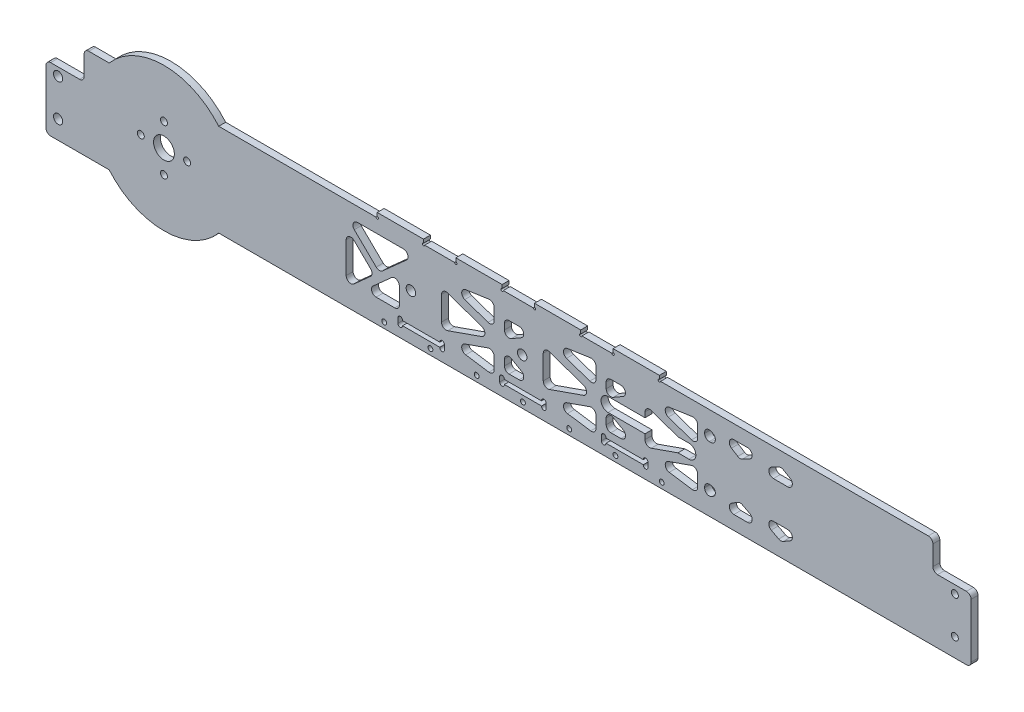
from build123d import *

# Parameters (mm, degrees)
SKETCH_1_W           = 368
SKETCH_1_H           = 40
EXTRUDE_1_DEPTH      = 3
SKETCH_2_W           = 16
SKETCH_2_H           = 27.5
EXTRUDE_2_DEPTH      = 3
SKETCH_3_R           = 4.5
SKETCH_3_R_2         = 1.5
SKETCH_3_R_3         = 3
SKETCH_3_R_4         = 2
CUT_EXTRUDE_1_DEPTH  = 4
SKETCH_5_R           = 1.5
CUT_EXTRUDE_3_DEPTH  = 3
SKETCH_6_W           = 0.5
SKETCH_6_H           = 12.5
CUT_EXTRUDE_4_DEPTH  = 10
SKETCH_8_R           = 31
SKETCH_8_R_2         = 1.5
SKETCH_8_R_3         = 4.5
EXTRUDE_3_DEPTH      = 3
CUT_EXTRUDE_7_DEPTH  = 10
SKETCH_11_R          = 2.05
CUT_EXTRUDE_8_DEPTH  = 10
SKETCH_12_R          = 1.05
CUT_EXTRUDE_9_DEPTH  = 10
SKETCH_14_W          = 20
SKETCH_14_H          = 2
EXTRUDE_4_DEPTH      = 3
SKETCH_15_W          = 20.1
SKETCH_15_H          = 2.1
CUT_EXTRUDE_10_DEPTH = 4
CUT_EXTRUDE_11_DEPTH = 10
SKETCH_17_R          = 1
CUT_EXTRUDE_12_DEPTH = 10
FILLET_1_R           = 2
SKETCH_18_W          = 16.1
SKETCH_18_H          = 0.1
EXTRUDE_5_DEPTH      = 3
SKETCH_19_R          = 0.5
CUT_EXTRUDE_13_DEPTH = 10


with BuildPart() as part:
    # 草图1 → 凸台-拉伸1 (new body)
    with BuildSketch(Plane.XY):
        Rectangle(SKETCH_1_W, SKETCH_1_H)
    extrude(amount=EXTRUDE_1_DEPTH)

    # 草图2 → 凸台-拉伸2 (add)
    with BuildSketch(Plane.XY):
        with Locations((-192, -6.25)):
            Rectangle(SKETCH_2_W, SKETCH_2_H)
        with Locations((192, -6.25)):
            Rectangle(SKETCH_2_W, SKETCH_2_H)
    extrude(amount=EXTRUDE_2_DEPTH)

    # 草图3 → 切除-拉伸1 (cut, through all)
    with BuildSketch(Plane.XY.offset(3)):
        with Locations((-149, 0)):
            Circle(SKETCH_3_R)
        with Locations((193, 4)):
            Circle(SKETCH_3_R_2)
        with Locations((193, -12)):
            Circle(SKETCH_3_R_2)
        with Locations((68, 0)):
            Circle(SKETCH_3_R_3)
        with Locations((-194.762498553, -12)):
            Circle(SKETCH_3_R_4)
        with Locations((-194.762498553, 4)):
            Circle(SKETCH_3_R_4)
    extrude(amount=-CUT_EXTRUDE_1_DEPTH, mode=Mode.SUBTRACT)

    # 草图5 → 切除-拉伸3 (cut)
    with BuildSketch(Plane.XY.offset(3)):
        with Locations((-159, 0)):
            Circle(SKETCH_5_R)
        with Locations((-149, 10)):
            Circle(SKETCH_5_R)
        with Locations((-139, 0)):
            Circle(SKETCH_5_R)
        with Locations((-149, -10)):
            Circle(SKETCH_5_R)
    extrude(amount=-CUT_EXTRUDE_3_DEPTH, mode=Mode.SUBTRACT)

    # 草图6 → 切除-拉伸4 (cut)
    with BuildSketch(Plane.XY.offset(3)):
        with Locations((-183.75, 13.75)):
            Rectangle(SKETCH_6_W, SKETCH_6_H)
        with Locations((183.75, 13.75)):
            Rectangle(SKETCH_6_W, SKETCH_6_H)
    extrude(amount=-CUT_EXTRUDE_4_DEPTH, mode=Mode.SUBTRACT)

    # 草图8 → 凸台-拉伸3 (add)
    with BuildSketch(Plane.XY.offset(3)):
        with Locations((-149, 0)):
            Circle(SKETCH_8_R)
        with Locations((-139, 0)):
            Circle(SKETCH_8_R_2, mode=Mode.SUBTRACT)
        with Locations((-149, -10)):
            Circle(SKETCH_8_R_2, mode=Mode.SUBTRACT)
        with Locations((-159, 0)):
            Circle(SKETCH_8_R_2, mode=Mode.SUBTRACT)
        with Locations((-149, 10)):
            Circle(SKETCH_8_R_2, mode=Mode.SUBTRACT)
        with Locations((-149, 0)):
            Circle(SKETCH_8_R_3, mode=Mode.SUBTRACT)
    extrude(amount=-EXTRUDE_3_DEPTH)

    # 草图10 → 切除-拉伸7 (cut)
    with BuildSketch(Plane.XY.offset(3)):
        with BuildLine():
            Line((43, 3), (78, 3))
            ThreePointArc((78, 3), (81, 0), (78, -3))
            Line((78, -3), (43, -3))
            ThreePointArc((43, -3), (40, 0), (43, 3))
        make_face()
    extrude(amount=-CUT_EXTRUDE_7_DEPTH, mode=Mode.SUBTRACT)

    # 草图11 → 切除-拉伸8 (cut)
    with BuildSketch(Plane(origin=(0, 0, 0), x_dir=(-1, 0, 0), z_dir=(0, 0, -1))):
        with Locations((-53.224408026, 0)):
            Circle(SKETCH_11_R)
        with Locations((42.205591974, 0)):
            Circle(SKETCH_11_R)
        with Locations((-5.901908026, 0)):
            Circle(SKETCH_11_R)
    extrude(amount=-CUT_EXTRUDE_8_DEPTH, mode=Mode.SUBTRACT)

    # 草图12 → 切除-拉伸9 (cut)
    with BuildSketch(Plane(origin=(0, 0, 0), x_dir=(-1, 0, 0), z_dir=(0, 0, -1))):
        with Locations((-66.224408026, -17.5)):
            Circle(SKETCH_12_R)
        with Locations((-46.224408026, -17.5)):
            Circle(SKETCH_12_R)
        with Locations((-26.224408026, -17.5)):
            Circle(SKETCH_12_R)
        with Locations((-6.224408026, -17.5)):
            Circle(SKETCH_12_R)
        with Locations((13.775591974, -17.5)):
            Circle(SKETCH_12_R)
        with Locations((33.775591974, -17.5)):
            Circle(SKETCH_12_R)
        with Locations((53.775591974, -17.5)):
            Circle(SKETCH_12_R)
    extrude(amount=-CUT_EXTRUDE_9_DEPTH, mode=Mode.SUBTRACT)

    # 草图14 → 凸台-拉伸4 (add)
    with BuildSketch(Plane.XY.offset(3)):
        with Locations((55.224408026, 21)):
            Rectangle(SKETCH_14_W, SKETCH_14_H)
        with Locations((21.224408026, 21)):
            Rectangle(SKETCH_14_W, SKETCH_14_H)
        with Locations((-12.775591974, 21)):
            Rectangle(SKETCH_14_W, SKETCH_14_H)
        with Locations((-46.775591974, 21)):
            Rectangle(SKETCH_14_W, SKETCH_14_H)
    extrude(amount=-EXTRUDE_4_DEPTH)

    # 草图15 → 切除-拉伸10 (cut, through all)
    with BuildSketch(Plane.XY.offset(3)):
        with Locations((50.224408026, -14)):
            Rectangle(SKETCH_15_W, SKETCH_15_H)
        with Locations((6.224408026, -14)):
            Rectangle(SKETCH_15_W, SKETCH_15_H)
        with Locations((-37.775591974, -14)):
            Rectangle(SKETCH_15_W, SKETCH_15_H)
    extrude(amount=-CUT_EXTRUDE_10_DEPTH, mode=Mode.SUBTRACT)

    # 草图16 → 切除-拉伸11 (cut)
    with BuildSketch(Plane(origin=(0, 0, 0), x_dir=(-1, 0, 0), z_dir=(0, 0, -1))):
        with BuildLine():
            Line((-104.299524502, 10.233433981), (-101.10955932, 8.540223685))
            ThreePointArc((-101.10955932, 8.540223685), (-100.102484581, 8.307993961), (-99.113940393, 8.609507749))
            Line((-99.113940393, 8.609507749), (-96.397473263, 10.302718045))
            ThreePointArc((-96.397473263, 10.302718045), (-95.532580053, 12.550198187), (-97.455411807, 14))
            Line((-97.455411807, 14), (-103.36184412, 14))
            ThreePointArc((-103.36184412, 14), (-105.302608408, 12.48315006), (-104.299524502, 10.233433981))
        make_face()
        with BuildLine():
            Line((-113.586675144, 11.766566019), (-116.81600985, 13.480673371))
            ThreePointArc((-116.81600985, 13.480673371), (-117.789309871, 13.713790137), (-118.753690233, 13.44615816))
            Line((-118.753690233, 13.44615816), (-121.722611256, 11.732050808))
            ThreePointArc((-121.722611256, 11.732050808), (-122.654462909, 9.48236191), (-120.722611256, 8))
            Line((-120.722611256, 8), (-114.524355526, 8))
            ThreePointArc((-114.524355526, 8), (-112.583591239, 9.51684994), (-113.586675144, 11.766566019))
        make_face()
        with BuildLine():
            Line((-49.584424063, 6.270311383), (-45.232211414, 3.743861811))
            ThreePointArc((-45.232211414, 3.743861811), (-43.23017334, 3.740322135), (-42.228131095, 5.473550429))
            Line((-42.228131095, 5.473550429), (-42.228131095, 8))
            ThreePointArc((-42.228131095, 8), (-42.813917532, 9.414213562), (-44.228131095, 10))
            Line((-44.228131095, 10), (-48.580343744, 10))
            ThreePointArc((-48.580343744, 10), (-50.51158392, 8.519914784), (-49.584424063, 6.270311383))
        make_face()
        with BuildLine():
            Line((-59.009408026, -5.178088408), (-59.009408026, 5.178088408))
            ThreePointArc((-59.009408026, 5.178088408), (-59.85293214, 6.809824762), (-61.671971552, 7.065152152))
            Line((-61.671971552, 7.065152152), (-76.4198146, 1.887063744))
            ThreePointArc((-76.4198146, 1.887063744), (-77.757251074, 0), (-76.4198146, -1.887063744))
            Line((-76.4198146, -1.887063744), (-61.671971552, -7.065152152))
            ThreePointArc((-61.671971552, -7.065152152), (-59.85293214, -6.809824762), (-59.009408026, -5.178088408))
        make_face()
        with BuildLine():
            Line((-79.131844499, 4.791990705), (-69.094439101, 8.316205898))
            ThreePointArc((-69.094439101, 8.316205898), (-67.766139944, 10.394229783), (-69.465227173, 12.181871948))
            Line((-69.465227173, 12.181871948), (-79.502632571, 13.662042329))
            ThreePointArc((-79.502632571, 13.662042329), (-81.10139867, 13.197301132), (-81.794408026, 11.683440024))
            Line((-81.794408026, 11.683440024), (-81.794408026, 6.679054449))
            ThreePointArc((-81.794408026, 6.679054449), (-80.950883911, 5.047318096), (-79.131844499, 4.791990705))
        make_face()
        with BuildLine():
            Line((-87.430787839, 8), (-86.794408026, 8))
            ThreePointArc((-86.794408026, 8), (-85.380194463, 8.585786438), (-84.794408026, 10))
            Line((-84.794408026, 10), (-84.794408026, 10.396664049))
            ThreePointArc((-84.794408026, 10.396664049), (-85.823809522, 12.145360291), (-87.85234657, 12.093946005))
            Line((-87.85234657, 12.093946005), (-88.488726383, 11.697281955))
            ThreePointArc((-88.488726383, 11.697281955), (-89.353619593, 9.449801813), (-87.430787839, 8))
        make_face()
        with BuildLine():
            Line((58.591786114, -6.45888277), (50.538472091, 0.739814907))
            ThreePointArc((50.538472091, 0.739814907), (48.388817903, 1.074315413), (47.205591974, -0.751302323))
            Line((47.205591974, -0.751302323), (47.205591974, -7.95))
            ThreePointArc((47.205591974, -7.95), (47.791378412, -9.364213562), (49.205591974, -9.95))
            Line((49.205591974, -9.95), (57.258905997, -9.95))
            ThreePointArc((57.258905997, -9.95), (59.127359162, -8.663360197), (58.591786114, -6.45888277))
        make_face()
        with BuildLine():
            Line((59.705451363, -3.430537552), (66.872711857, -9.837209554))
            ThreePointArc((66.872711857, -9.837209554), (69.022366045, -10.17171006), (70.205591974, -8.346092324))
            Line((70.205591974, -8.346092324), (70.205591974, 5.058907845))
            ThreePointArc((70.205591974, 5.058907845), (68.981962411, 6.902070601), (66.808343029, 6.489884919))
            Line((66.808343029, 6.489884919), (59.641082535, -0.508443249))
            ThreePointArc((59.641082535, -0.508443249), (59.038816551, -1.983466277), (59.705451363, -3.430537552))
        make_face()
        with BuildLine():
            Line((65.294545755, 14), (45.444048433, 14))
            ThreePointArc((45.444048433, 14), (43.575595268, 12.713360197), (44.111168316, 10.50888277))
            Line((44.111168316, 10.50888277), (54.474487435, 1.245317353))
            ThreePointArc((54.474487435, 1.245317353), (55.851413506, 0.736919653), (57.204616497, 1.305457509))
            Line((57.204616497, 1.305457509), (66.6917947, 10.569022926))
            ThreePointArc((66.6917947, 10.569022926), (67.146835439, 12.754336083), (65.294545755, 14))
        make_face()
        with BuildLine():
            Line((-44.228131095, -10), (-48.580343744, -10))
            ThreePointArc((-48.580343744, -10), (-50.51158392, -8.519914784), (-49.584424063, -6.270311383))
            Line((-49.584424063, -6.270311383), (-45.232211414, -3.743861811))
            ThreePointArc((-45.232211414, -3.743861811), (-43.23017334, -3.740322135), (-42.228131095, -5.473550429))
            Line((-42.228131095, -5.473550429), (-42.228131095, -8))
            ThreePointArc((-42.228131095, -8), (-42.813917532, -9.414213562), (-44.228131095, -10))
        make_face()
        with BuildLine():
            Line((-79.131844499, -4.791990705), (-69.094439101, -8.316205898))
            ThreePointArc((-69.094439101, -8.316205898), (-67.766139944, -10.394229783), (-69.465227173, -12.181871948))
            Line((-69.465227173, -12.181871948), (-79.502632571, -13.662042329))
            ThreePointArc((-79.502632571, -13.662042329), (-81.10139867, -13.197301132), (-81.794408026, -11.683440024))
            Line((-81.794408026, -11.683440024), (-81.794408026, -6.679054449))
            ThreePointArc((-81.794408026, -6.679054449), (-80.950883911, -5.047318096), (-79.131844499, -4.791990705))
        make_face()
        with BuildLine():
            Line((-104.299524502, -10.233433981), (-101.10955932, -8.540223685))
            ThreePointArc((-101.10955932, -8.540223685), (-100.102484581, -8.307993961), (-99.113940393, -8.609507749))
            Line((-99.113940393, -8.609507749), (-96.397473263, -10.302718045))
            ThreePointArc((-96.397473263, -10.302718045), (-95.532580053, -12.550198187), (-97.455411807, -14))
            Line((-97.455411807, -14), (-103.36184412, -14))
            ThreePointArc((-103.36184412, -14), (-105.302608408, -12.48315006), (-104.299524502, -10.233433981))
        make_face()
        with BuildLine():
            Line((-120.722611256, -8), (-114.524355526, -8))
            ThreePointArc((-114.524355526, -8), (-112.583591239, -9.51684994), (-113.586675144, -11.766566019))
            Line((-113.586675144, -11.766566019), (-116.81600985, -13.480673371))
            ThreePointArc((-116.81600985, -13.480673371), (-117.789309871, -13.713790137), (-118.753690233, -13.44615816))
            Line((-118.753690233, -13.44615816), (-121.722611256, -11.732050808))
            ThreePointArc((-121.722611256, -11.732050808), (-122.654462909, -9.48236191), (-120.722611256, -8))
        make_face()
        with BuildLine():
            Line((-87.85234657, -12.093946005), (-88.488726383, -11.697281955))
            ThreePointArc((-88.488726383, -11.697281955), (-89.353619593, -9.449801813), (-87.430787839, -8))
            Line((-87.430787839, -8), (-86.794408026, -8))
            ThreePointArc((-86.794408026, -8), (-85.380194463, -8.585786438), (-84.794408026, -10))
            Line((-84.794408026, -10), (-84.794408026, -10.396664049))
            ThreePointArc((-84.794408026, -10.396664049), (-85.823809522, -12.145360291), (-87.85234657, -12.093946005))
        make_face()
        with BuildLine():
            Line((-35.131844499, 4.791990705), (-25.094439101, 8.316205898))
            ThreePointArc((-25.094439101, 8.316205898), (-23.766139944, 10.394229783), (-25.465227173, 12.181871948))
            Line((-25.465227173, 12.181871948), (-35.502632571, 13.662042329))
            ThreePointArc((-35.502632571, 13.662042329), (-37.10139867, 13.197301132), (-37.794408026, 11.683440024))
            Line((-37.794408026, 11.683440024), (-37.794408026, 6.679054449))
            ThreePointArc((-37.794408026, 6.679054449), (-36.950883911, 5.047318096), (-35.131844499, 4.791990705))
        make_face()
        with BuildLine():
            Line((-17.671971552, 7.065152152), (-32.4198146, 1.887063744))
            ThreePointArc((-32.4198146, 1.887063744), (-33.757251074, 0), (-32.4198146, -1.887063744))
            Line((-32.4198146, -1.887063744), (-17.671971552, -7.065152152))
            ThreePointArc((-17.671971552, -7.065152152), (-15.85293214, -6.809824762), (-15.009408026, -5.178088408))
            Line((-15.009408026, -5.178088408), (-15.009408026, 5.178088408))
            ThreePointArc((-15.009408026, 5.178088408), (-15.85293214, 6.809824762), (-17.671971552, 7.065152152))
        make_face()
        with BuildLine():
            Line((-35.131844499, -4.791990705), (-25.094439101, -8.316205898))
            ThreePointArc((-25.094439101, -8.316205898), (-23.766139944, -10.394229783), (-25.465227173, -12.181871948))
            Line((-25.465227173, -12.181871948), (-35.502632571, -13.662042329))
            ThreePointArc((-35.502632571, -13.662042329), (-37.10139867, -13.197301132), (-37.794408026, -11.683440024))
            Line((-37.794408026, -11.683440024), (-37.794408026, -6.679054449))
            ThreePointArc((-37.794408026, -6.679054449), (-36.950883911, -5.047318096), (-35.131844499, -4.791990705))
        make_face()
        with BuildLine():
            Line((-5.584424063, -6.270311383), (-1.232211414, -3.743861811))
            ThreePointArc((-1.232211414, -3.743861811), (0.76982666, -3.740322135), (1.771868905, -5.473550429))
            Line((1.771868905, -5.473550429), (1.771868905, -8))
            ThreePointArc((1.771868905, -8), (1.186082468, -9.414213562), (-0.228131095, -10))
            Line((-0.228131095, -10), (-4.580343744, -10))
            ThreePointArc((-4.580343744, -10), (-6.51158392, -8.519914784), (-5.584424063, -6.270311383))
        make_face()
        with BuildLine():
            Line((-5.584424063, 6.270311383), (-1.232211414, 3.743861811))
            ThreePointArc((-1.232211414, 3.743861811), (0.76982666, 3.740322135), (1.771868905, 5.473550429))
            Line((1.771868905, 5.473550429), (1.771868905, 8))
            ThreePointArc((1.771868905, 8), (1.186082468, 9.414213562), (-0.228131095, 10))
            Line((-0.228131095, 10), (-4.580343744, 10))
            ThreePointArc((-4.580343744, 10), (-6.51158392, 8.519914784), (-5.584424063, 6.270311383))
        make_face()
        with BuildLine():
            Line((8.868155501, 4.791990705), (18.905560899, 8.316205898))
            ThreePointArc((18.905560899, 8.316205898), (20.233860056, 10.394229783), (18.534772827, 12.181871948))
            Line((18.534772827, 12.181871948), (8.497367429, 13.662042329))
            ThreePointArc((8.497367429, 13.662042329), (6.89860133, 13.197301132), (6.205591974, 11.683440024))
            Line((6.205591974, 11.683440024), (6.205591974, 6.679054449))
            ThreePointArc((6.205591974, 6.679054449), (7.049116089, 5.047318096), (8.868155501, 4.791990705))
        make_face()
        with BuildLine():
            Line((26.328028448, 7.065152152), (11.5801854, 1.887063744))
            ThreePointArc((11.5801854, 1.887063744), (10.242748926, 0), (11.5801854, -1.887063744))
            Line((11.5801854, -1.887063744), (26.328028448, -7.065152152))
            ThreePointArc((26.328028448, -7.065152152), (28.14706786, -6.809824762), (28.990591974, -5.178088408))
            Line((28.990591974, -5.178088408), (28.990591974, 5.178088408))
            ThreePointArc((28.990591974, 5.178088408), (28.14706786, 6.809824762), (26.328028448, 7.065152152))
        make_face()
        with BuildLine():
            Line((8.868155501, -4.791990705), (18.905560899, -8.316205898))
            ThreePointArc((18.905560899, -8.316205898), (20.233860056, -10.394229783), (18.534772827, -12.181871948))
            Line((18.534772827, -12.181871948), (8.497367429, -13.662042329))
            ThreePointArc((8.497367429, -13.662042329), (6.89860133, -13.197301132), (6.205591974, -11.683440024))
            Line((6.205591974, -11.683440024), (6.205591974, -6.679054449))
            ThreePointArc((6.205591974, -6.679054449), (7.049116089, -5.047318096), (8.868155501, -4.791990705))
        make_face()
    extrude(amount=-CUT_EXTRUDE_11_DEPTH, mode=Mode.SUBTRACT)

    # 草图17 → 切除-拉伸12 (cut)
    with BuildSketch(Plane(origin=(0, 0, 0), x_dir=(-1, 0, 0), z_dir=(0, 0, -1))):
        with Locations((-59.274408026, -12.95)):
            Circle(SKETCH_17_R)
        with Locations((-59.274408026, -15.05)):
            Circle(SKETCH_17_R)
        with Locations((-41.174408026, -15.05)):
            Circle(SKETCH_17_R)
        with Locations((-41.174408026, -12.95)):
            Circle(SKETCH_17_R)
        with Locations((-15.274408026, -12.95)):
            Circle(SKETCH_17_R)
        with Locations((-15.274408026, -15.05)):
            Circle(SKETCH_17_R)
        with Locations((2.825591974, -12.95)):
            Circle(SKETCH_17_R)
        with Locations((2.825591974, -15.05)):
            Circle(SKETCH_17_R)
        with Locations((28.725591974, -12.95)):
            Circle(SKETCH_17_R)
        with Locations((28.725591974, -15.05)):
            Circle(SKETCH_17_R)
        with Locations((46.825591974, -12.95)):
            Circle(SKETCH_17_R)
        with Locations((46.825591974, -15.05)):
            Circle(SKETCH_17_R)
    extrude(amount=-CUT_EXTRUDE_12_DEPTH, mode=Mode.SUBTRACT)

    # 圆角1
    fillet_1_edges = [part.edges().sort_by_distance(p)[0] for p in [
        (-183.5, 20, 1.5),
        (-183.5, 7.5, 1.5),
        (183.5, 7.5, 1.5),
        (183.5, 20, 1.5),
        (-200, 7.5, 1.5),
        (-200, -20, 1.5),
        (200, -20, 1.5),
        (200, 7.5, 1.5),
    ]]
    fillet(fillet_1_edges, radius=FILLET_1_R)

    # 草图18 → 凸台-拉伸5 (add)
    with BuildSketch(Plane(origin=(0, 0, 0), x_dir=(-1, 0, 0), z_dir=(0, 0, -1))):
        with Locations((-50.224408026, -13)):
            Rectangle(SKETCH_18_W, SKETCH_18_H)
        with Locations((-50.224408026, -15)):
            Rectangle(SKETCH_18_W, SKETCH_18_H)
        with Locations((-6.224408026, -13)):
            Rectangle(SKETCH_18_W, SKETCH_18_H)
        with Locations((-6.224408026, -15)):
            Rectangle(SKETCH_18_W, SKETCH_18_H)
        with Locations((37.775591974, -13)):
            Rectangle(SKETCH_18_W, SKETCH_18_H)
        with Locations((37.775591974, -15)):
            Rectangle(SKETCH_18_W, SKETCH_18_H)
    extrude(amount=-EXTRUDE_5_DEPTH)

    # 草图19 → 切除-拉伸13 (cut)
    with BuildSketch(Plane.XY.offset(3)):
        with Locations((-56.775591974, 20)):
            Circle(SKETCH_19_R)
        with Locations((-36.775591974, 20)):
            Circle(SKETCH_19_R)
        with Locations((-22.775591974, 20)):
            Circle(SKETCH_19_R)
        with Locations((-2.775591974, 20)):
            Circle(SKETCH_19_R)
        with Locations((11.224408026, 20)):
            Circle(SKETCH_19_R)
        with Locations((31.224408026, 20)):
            Circle(SKETCH_19_R)
        with Locations((45.224408026, 20)):
            Circle(SKETCH_19_R)
        with Locations((65.224408026, 20)):
            Circle(SKETCH_19_R)
    extrude(amount=-CUT_EXTRUDE_13_DEPTH, mode=Mode.SUBTRACT)


solid = part.part
